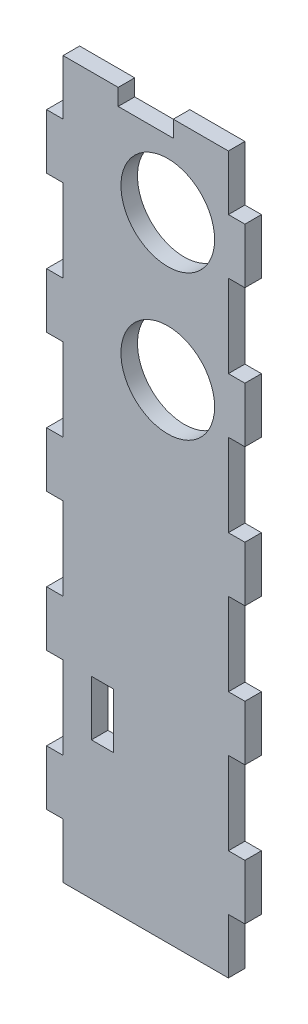
from build123d import *

# Parameters (mm, degrees)
ESQUISSE1_R        = 8.5
ESQUISSE1_W        = 4
ESQUISSE1_H        = 10
BOSS_EXTRU_1_DEPTH = 3


with BuildPart() as part:
    # Esquisse1 → Boss.-Extru.1 (new body)
    with BuildSketch(Plane.XY):
        Polygon((2.029381216, -75.048859935), (-27.970618784, -75.048859935), (-27.970618784, -65.048859935), (-30.970618784, -65.048859935), (-30.970618784, -55.048859935), (-27.970618784, -55.048859935), (-27.970618784, -40.048859935), (-30.970618784, -40.048859935), (-30.970618784, -30.048859935), (-27.970618784, -30.048859935), (-27.970618784, -15.048859935), (-30.970618784, -15.048859935), (-30.970618784, -5.048859935), (-27.970618784, -5.048859935), (-27.970618784, 9.951140065), (-30.970618784, 9.951140065), (-30.970618784, 19.951140065), (-27.970618784, 19.951140065), (-27.970618784, 34.951140065), (-30.970618784, 34.951140065), (-30.970618784, 44.951140065), (-27.970618784, 44.951140065), (-27.970618784, 54.951140065), (-17.970618784, 54.951140065), (-17.970618784, 51.951140065), (-7.970618784, 51.951140065), (-7.970618784, 54.951140065), (2.029381216, 54.951140065), (2.029381216, 44.951140065), (5.029381216, 44.951140065), (5.029381216, 34.951140065), (2.029381216, 34.951140065), (2.029381216, 19.951140065), (5.029381216, 19.951140065), (5.029381216, 9.951140065), (2.029381216, 9.951140065), (2.029381216, -5.048859935), (5.029381216, -5.048859935), (5.029381216, -15.048859935), (2.029381216, -15.048859935), (2.029381216, -30.048859935), (5.029381216, -30.048859935), (5.029381216, -40.048859935), (2.029381216, -40.048859935), (2.029381216, -55.048859935), (5.029381216, -55.048859935), (5.029381216, -65.048859935), (2.029381216, -65.048859935), align=None)
        with Locations((-8.970618784, 39.768013852)):
            Circle(ESQUISSE1_R, mode=Mode.SUBTRACT)
        with Locations((-8.970618784, 13.468013852)):
            Circle(ESQUISSE1_R, mode=Mode.SUBTRACT)
        with Locations((-20.834297512, -45.048859935)):
            Rectangle(ESQUISSE1_W, ESQUISSE1_H, mode=Mode.SUBTRACT)
    extrude(amount=BOSS_EXTRU_1_DEPTH)


solid = part.part
